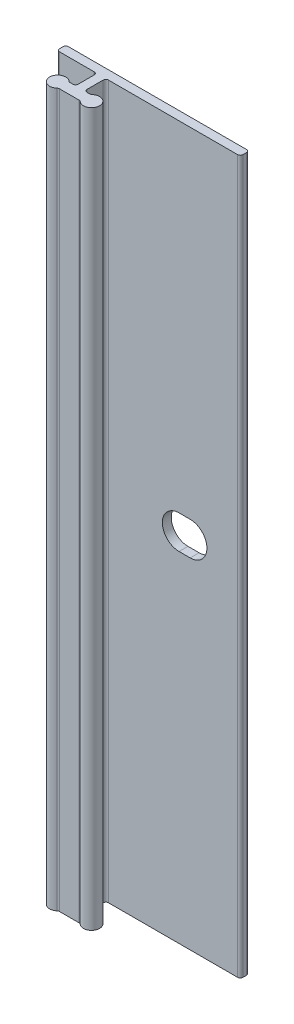
from build123d import *

# Parameters (mm, degrees)
BOSS_EXTRUDE1_DEPTH = 50.8
CUT_EXTRUDE1_DEPTH  = 2.27


with BuildPart() as part:
    # Sketch2 → Boss-Extrude1 (new body, symmetric)
    with BuildSketch(Plane(origin=(0, 0, 0), x_dir=(1, 0, 0), z_dir=(0, 1, 0))):
        with BuildLine():
            Line((-5.969, 0), (19.431, 0))
            ThreePointArc((19.431, 0), (19.700407684, -0.111592316), (19.812, -0.381))
            Line((19.812, -0.381), (19.812, -0.889))
            ThreePointArc((19.812, -0.889), (19.700407684, -1.158407684), (19.431, -1.27))
            Line((19.431, -1.27), (1.016, -1.27))
            ThreePointArc((1.016, -1.27), (0.746592316, -1.381592316), (0.635, -1.651))
            Line((0.635, -1.651), (0.635, -3.937))
            ThreePointArc((0.635, -3.937), (0.746592316, -4.206407684), (1.016, -4.318))
            Line((1.016, -4.318), (1.40496875, -4.318))
            ThreePointArc((1.40496875, -4.318), (1.539672592, -4.293392866), (1.656976563, -4.22275))
            ThreePointArc((1.656976563, -4.22275), (3.556, -5.08), (1.656976563, -5.93725))
            ThreePointArc((1.656976563, -5.93725), (1.539672592, -5.866607134), (1.40496875, -5.842))
            Line((1.40496875, -5.842), (-1.40496875, -5.842))
            ThreePointArc((-1.40496875, -5.842), (-1.539672592, -5.866607134), (-1.656976563, -5.93725))
            ThreePointArc((-1.656976563, -5.93725), (-3.556, -5.08), (-1.656976563, -4.22275))
            ThreePointArc((-1.656976563, -4.22275), (-1.539672592, -4.293392866), (-1.40496875, -4.318))
            Line((-1.40496875, -4.318), (-1.016, -4.318))
            ThreePointArc((-1.016, -4.318), (-0.746592316, -4.206407684), (-0.635, -3.937))
            Line((-0.635, -3.937), (-0.635, -1.651))
            ThreePointArc((-0.635, -1.651), (-0.746592316, -1.381592316), (-1.016, -1.27))
            Line((-1.016, -1.27), (-5.969, -1.27))
            ThreePointArc((-5.969, -1.27), (-6.238407684, -1.158407684), (-6.35, -0.889))
            Line((-6.35, -0.889), (-6.35, -0.381))
            ThreePointArc((-6.35, -0.381), (-6.238407684, -0.111592316), (-5.969, 0))
        make_face()
    extrude(amount=BOSS_EXTRUDE1_DEPTH, both=True)

    # Sketch3 → Cut-Extrude1 (cut, through all)
    with BuildSketch(Plane.XY.offset(1.27)):
        with BuildLine():
            Line((11.08075, 2.38125), (12.66825, 2.38125))
            ThreePointArc((12.66825, 2.38125), (15.0495, 0), (12.66825, -2.38125))
            Line((12.66825, -2.38125), (11.08075, -2.38125))
            ThreePointArc((11.08075, -2.38125), (8.6995, 0), (11.08075, 2.38125))
        make_face()
    extrude(amount=-CUT_EXTRUDE1_DEPTH, mode=Mode.SUBTRACT)


solid = part.part
